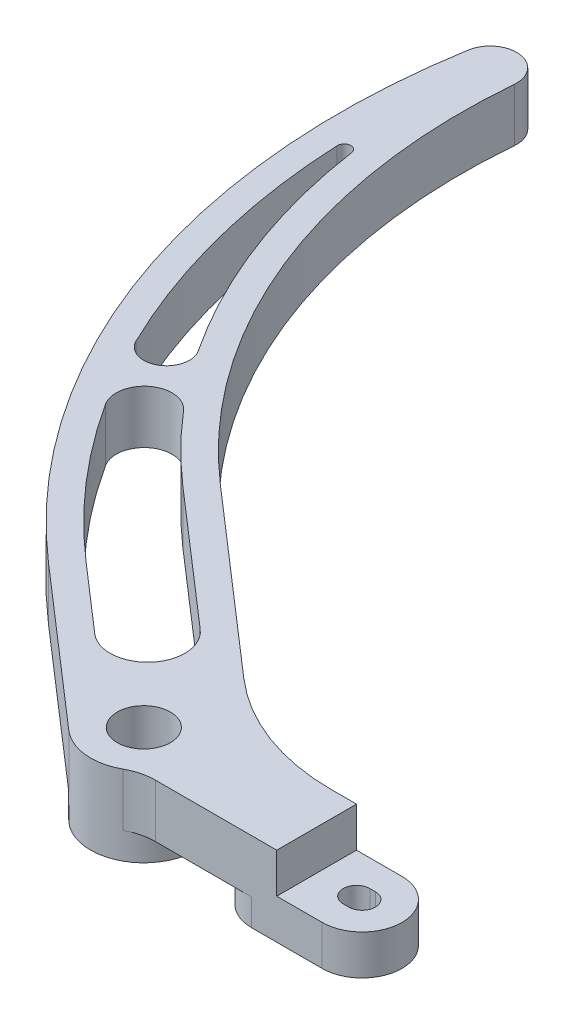
from build123d import *

# Parameters (mm, degrees)
SKETCH1_R           = 6.35
BOSS_EXTRUDE1_DEPTH = 12.7
CUT_EXTRUDE2_DEPTH  = 13.7
FILLET1_R           = 12.7
SKETCH4_R           = 12.7
SKETCH4_R_2         = 6.35
BOSS_EXTRUDE2_DEPTH = 6.35
SKETCH2_W           = 27.073872012
SKETCH2_H           = 29.596885175
CUT_EXTRUDE1_DEPTH  = 9.525


with BuildPart() as part:
    # Sketch1 → Boss-Extrude1 (new body)
    with BuildSketch(Plane(origin=(0, 0, 0), x_dir=(1, 0, 0), z_dir=(0, 1, 0))):
        with BuildLine():
            Line((1.339902706, -174.625), (-42.399739587, -174.625))
            ThreePointArc((-42.399739587, -174.625), (-50.754602331, -177.79991886), (-59.131949668, -174.684811669))
            Line((-59.131949668, -174.684811669), (-96.253765638, -142.415309363))
            ThreePointArc((-96.253765638, -142.415309363), (-144.617963608, -71.634466036), (-152.13989844, 13.761341376))
            ThreePointArc((-152.13989844, 13.761341376), (-145.072520944, 18.99854995), (-139.553151074, 12.149262793))
            ThreePointArc((-139.553151074, 12.149262793), (-129.869632709, -52.503000495), (-91.90140484, -105.720472707))
            Line((-91.90140484, -105.720472707), (-48.88478864, -143.114246675))
            ThreePointArc((-48.88478864, -143.114246675), (-33.347524936, -152.357947214), (-15.556989968, -155.575))
            Line((-15.556989968, -155.575), (1.339902706, -155.575))
            ThreePointArc((1.339902706, -155.575), (10.864902706, -165.1), (1.339902706, -174.625))
        make_face()
        with Locations((-50.8, -165.1)):
            Circle(SKETCH1_R, mode=Mode.SUBTRACT)
        with BuildLine():
            Line((0, -161.925), (1.339902706, -161.925))
            ThreePointArc((1.339902706, -161.925), (4.514902706, -165.1), (1.339902706, -168.275))
            Line((1.339902706, -168.275), (0, -168.275))
            ThreePointArc((0, -168.275), (-3.175, -165.1), (0, -161.925))
        make_face(mode=Mode.SUBTRACT)
    extrude(amount=BOSS_EXTRUDE1_DEPTH)

    # Sketch3 → Cut-Extrude2 (cut, through all)
    with BuildSketch(Plane(origin=(0, 12.7, 0), x_dir=(1, 0, 0), z_dir=(0, 1, 0))):
        with BuildLine():
            Line((-64.278893585, -138.146187914), (-96.067379674, -110.512878542))
            ThreePointArc((-96.067379674, -110.512878542), (-104.093661598, -102.988093371), (-111.532318829, -94.88192461))
            ThreePointArc((-111.532318829, -94.88192461), (-120.588765116, -93.847414192), (-122.222718656, -102.815113283))
            ThreePointArc((-122.222718656, -102.815113283), (-108.389889378, -121.287896312), (-92.087790804, -137.622903528))
            Line((-92.087790804, -137.622903528), (-75.989121055, -151.617263638))
            ThreePointArc((-75.989121055, -151.617263638), (-63.398469458, -150.736839511), (-64.278893585, -138.146187914))
        make_face()
        with BuildLine():
            ThreePointArc((-122.168303836, -80.727586976), (-124.013598755, -88.474110491), (-131.62448434, -86.131428157))
            ThreePointArc((-131.62448434, -86.131428157), (-143.140144863, -54.755391727), (-148.016867664, -21.690551276))
            ThreePointArc((-148.016867664, -21.690551276), (-146.581764091, -20.040770563), (-144.860415421, -21.389198324))
            ThreePointArc((-144.860415421, -21.389198324), (-136.771142128, -52.303847297), (-122.168303836, -80.727586976))
        make_face()
    extrude(amount=-CUT_EXTRUDE2_DEPTH, mode=Mode.SUBTRACT)

    # Fillet1
    fillet1_edges = [part.edges().sort_by_distance(p)[0] for p in [
        (-42.399739587, 6.35, 174.625),
    ]]
    fillet(fillet1_edges, radius=FILLET1_R)

    # Sketch4 → Boss-Extrude2 (add)
    with BuildSketch(Plane(origin=(0, 0, 0), x_dir=(1, 0, 0), z_dir=(0, 1, 0))):
        with Locations((-50.8, -165.1)):
            Circle(SKETCH4_R)
        with Locations((-50.8, -165.1)):
            Circle(SKETCH4_R_2, mode=Mode.SUBTRACT)
        with BuildLine():
            Line((1.339902706, -174.625), (-15.556989968, -174.625))
            ThreePointArc((-15.556989968, -174.625), (-25.081989968, -165.1), (-15.556989968, -155.575))
            Line((-15.556989968, -155.575), (1.339902706, -155.575))
            ThreePointArc((1.339902706, -155.575), (10.864902706, -165.1), (1.339902706, -174.625))
        make_face()
        with BuildLine():
            Line((1.339902706, -161.925), (0, -161.925))
            ThreePointArc((0, -161.925), (-3.175, -165.1), (0, -168.275))
            Line((0, -168.275), (1.339902706, -168.275))
            ThreePointArc((1.339902706, -168.275), (4.514902706, -165.1), (1.339902706, -161.925))
        make_face(mode=Mode.SUBTRACT)
    extrude(amount=-BOSS_EXTRUDE2_DEPTH)

    # Sketch2 → Cut-Extrude1 (cut)
    with BuildSketch(Plane(origin=(0, 12.7, 0), x_dir=(1, 0, 0), z_dir=(0, 1, 0))):
        with Locations((4.011936006, -165.256904056)):
            Rectangle(SKETCH2_W, SKETCH2_H)
    extrude(amount=-CUT_EXTRUDE1_DEPTH, mode=Mode.SUBTRACT)


solid = part.part
